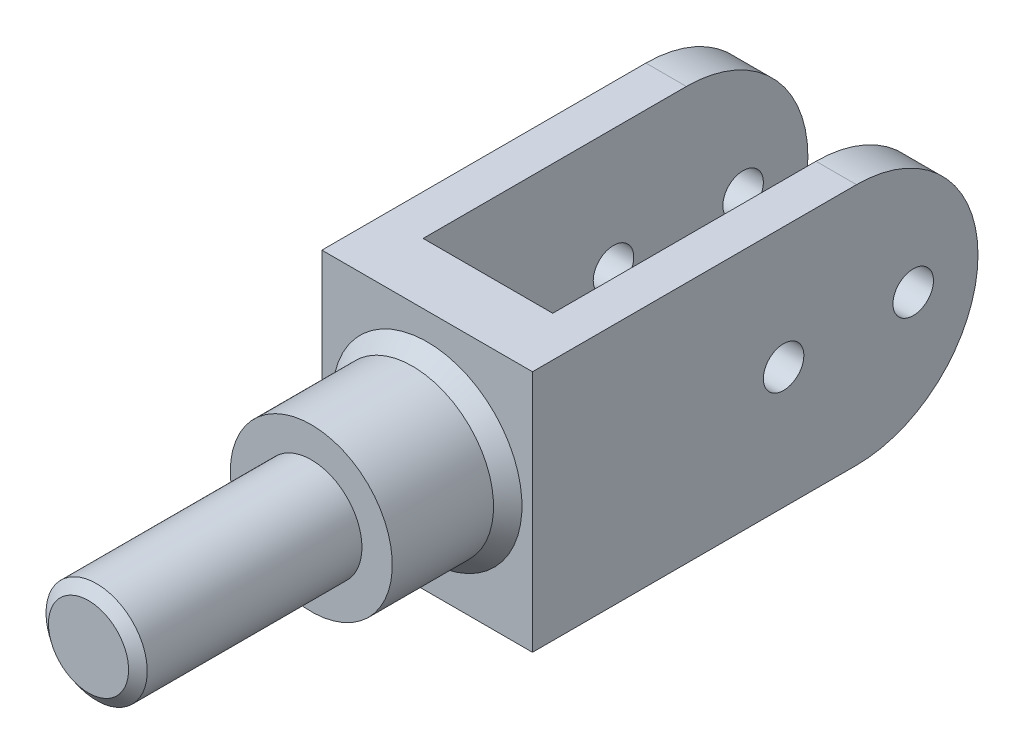
from build123d import *

# Parameters (mm, degrees)
BOSS_EXTRUDE1_DEPTH      = 5
BOSS_EXTRUDE1_DEPTH_BACK = 105
SKETCH5_W                = 32
SKETCH5_H                = 95
CUT_EXTRUDE1_DEPTH       = 100
CUT_EXTRUDE2_DEPTH       = 40
CUT_EXTRUDE2_DEPTH_BACK  = 113
SKETCH7_R                = 5
CUT_EXTRUDE4_DEPTH       = 234
CUT_EXTRUDE4_DEPTH_BACK  = 234


with BuildPart() as part:
    # Sketch2 → Revolve2 (revolve)
    with BuildSketch(Plane(origin=(0, 0, 0), x_dir=(0, 0, -1), z_dir=(1, 0, 0))):
        Polygon((15.054954353, -7.686097714), (-68.645045647, -7.686097714), (-68.645045647, 2.203003026), (-66.645045647, 4.813902286), (-13.645045647, 4.813902286), (-13.645045647, 12.313902286), (11.354954353, 12.313902286), (15.054954353, 15.806805515), align=None)
    revolve(axis=Axis((0, -7.686097714, -15.054954353), (0, 0, 1)))

    # 3DSketch2 → Boss-Extrude1 (add, two sides: drawn at the far end of the back side and taken through both)
    with BuildSketch(Plane(origin=(26.001222768, 22.321847461, -19.965853613), x_dir=(-0.6549305384178419, -0.7556890827898176, 0), z_dir=(0, 0, 1)).offset(-BOSS_EXTRUDE1_DEPTH_BACK)):
        Polygon((0, 0), (34.056387998, -39.295832305), (79.397732965, 0), (45.341344967, 39.295832305), align=None)
    extrude(amount=BOSS_EXTRUDE1_DEPTH + BOSS_EXTRUDE1_DEPTH_BACK)

    # Sketch5 → Cut-Extrude1 (cut)
    with BuildSketch(Plane(origin=(0, 22.321847461, 0), x_dir=(1, 0, 0), z_dir=(0, 1, 0))):
        with Locations((0.001222768, 77.465853613)):
            Rectangle(SKETCH5_W, SKETCH5_H)
    extrude(amount=-CUT_EXTRUDE1_DEPTH, mode=Mode.SUBTRACT)

    # Sketch7 → Cut-Extrude2 (cut, two sides: drawn at the far end of the back side and taken through both)
    with BuildSketch(Plane(origin=(26.001222768, 0, 0), x_dir=(0, 0, -1), z_dir=(1, 0, 0)).offset(-CUT_EXTRUDE2_DEPTH_BACK)):
        with Locations((76.965853613, -7.678152539)):
            Circle(SKETCH7_R)
        with Locations((108.965853613, -7.678152539)):
            Circle(SKETCH7_R)
    extrude(amount=CUT_EXTRUDE2_DEPTH + CUT_EXTRUDE2_DEPTH_BACK, mode=Mode.SUBTRACT)

    # Sketch8 → Cut-Extrude4 (cut, two sides: drawn at the far end of the back side and taken through both)
    with BuildSketch(Plane(origin=(26.001222768, 0, 0), x_dir=(0, 0, -1), z_dir=(1, 0, 0)).offset(-CUT_EXTRUDE4_DEPTH_BACK)):
        with BuildLine():
            Line((124.965853613, -37.678152539), (124.965853613, -7.678152493))
            ThreePointArc((124.965853613, -7.678152493), (116.179057065, -28.891355958), (94.965853613, -37.678152539))
            Line((94.965853613, -37.678152539), (124.965853613, -37.678152539))
        make_face()
        with BuildLine():
            Line((124.965853613, -7.678152493), (124.965853613, 22.321847461))
            Line((124.965853613, 22.321847461), (94.965853613, 22.321847461))
            ThreePointArc((94.965853613, 22.321847461), (116.179057032, 13.535050913), (124.965853613, -7.678152493))
        make_face()
    extrude(amount=CUT_EXTRUDE4_DEPTH + CUT_EXTRUDE4_DEPTH_BACK, mode=Mode.SUBTRACT)


solid = part.part
